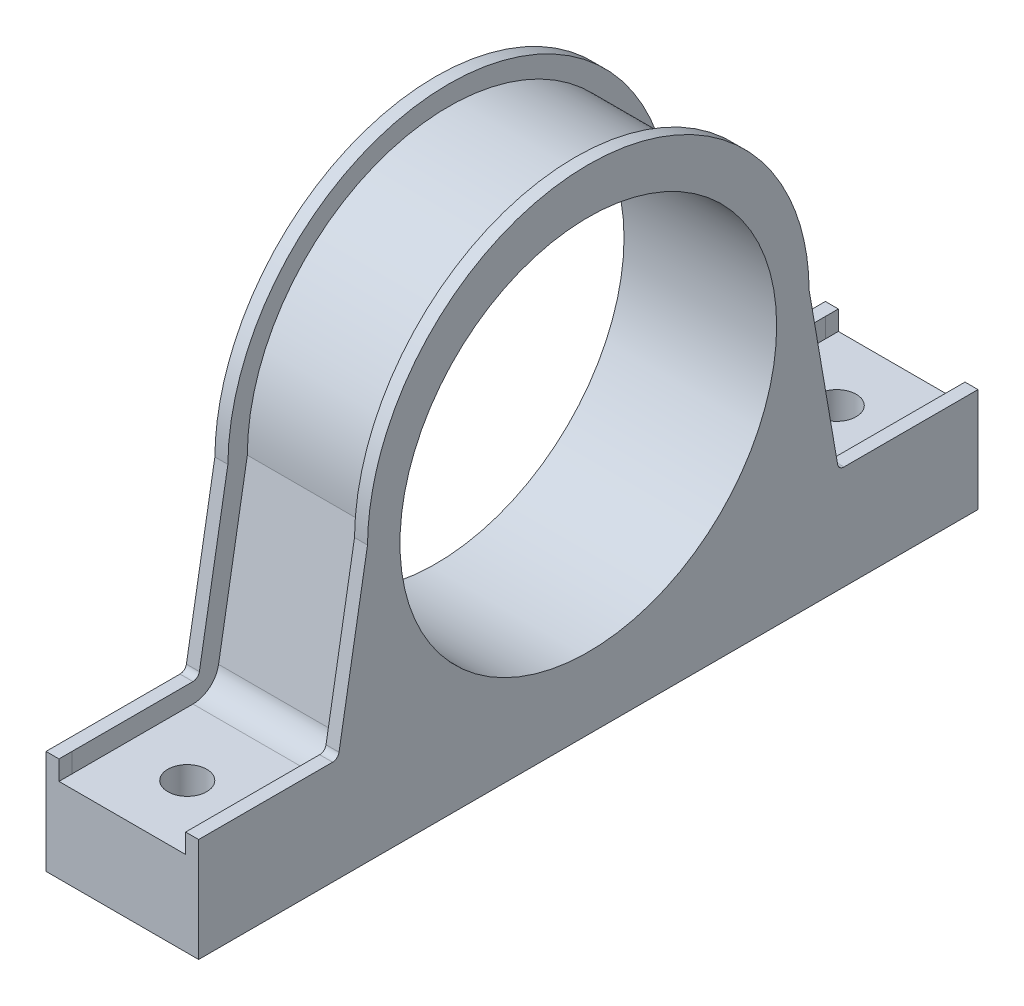
from build123d import *

# Parameters (mm, degrees)
SZKIC2_R                    = 29
DODANIE_WYCI_GNI_CIE2_DEPTH = 23.5
SZKIC3_R                    = 3
WYTNIJ_WYCI_GNI_CIE1_DEPTH  = 23.5
ZAOKR_GLENIE1_R             = 4
DODANIE_WYCI_GNI_CIE3_REACH = 82
WYTNIJ_WYCI_GNI_CIE2_DEPTH  = 23.5


with BuildPart() as part:
    # Szkic2 → Dodanie-wyciągnięcie2 (new body)
    with BuildSketch(Plane(origin=(0, 0, 0), x_dir=(0, 0, -1), z_dir=(1, 0, 0))):
        with BuildLine():
            Line((-60, -6.5), (60, -6.5))
            Line((60, -6.5), (60, 6.5))
            Line((60, 6.5), (36, 6.5))
            Line((36, 6.5), (31, 35.5))
            ThreePointArc((31, 35.5), (0, 66.5), (-31, 35.5))
            Line((-31, 35.5), (-36, 6.5))
            Line((-36, 6.5), (-60, 6.5))
            Line((-60, 6.5), (-60, -6.5))
        make_face()
        with Locations((0, 33.5)):
            Circle(SZKIC2_R, mode=Mode.SUBTRACT)
    extrude(amount=DODANIE_WYCI_GNI_CIE2_DEPTH)

    # Szkic3 → Wytnij-wyciągnięcie1 (cut)
    with BuildSketch(Plane(origin=(0, 6.5, 0), x_dir=(1, 0, 0), z_dir=(0, 1, 0))):
        with Locations((11.75, 50)):
            Circle(SZKIC3_R)
        with Locations((11.75, -50)):
            Circle(SZKIC3_R)
    extrude(amount=-WYTNIJ_WYCI_GNI_CIE1_DEPTH, mode=Mode.SUBTRACT)

    # Zaokrąglenie1
    zaokr_glenie1_edges = [part.edges().sort_by_distance(p)[0] for p in [
        (11.75, 6.5, -36),
        (11.75, 6.5, 36),
    ]]
    fillet(zaokr_glenie1_edges, radius=ZAOKR_GLENIE1_R)

    # Szkic4 → Dodanie-wyciągnięcie3 (add, up to next)
    with BuildSketch(Plane(origin=(0, 73.5, 0), x_dir=(-1, 0, 0), z_dir=(0, -1, 0)), mode=Mode.PRIVATE) as dodanie_wyci_gni_cie3_sk1:
        Polygon((0, 60), (0, 39.369362474), (0, 35.427522011), (0, 31), (0, -31), (0, -35.427522011), (0, -39.369362474), (0, -60), (-2, -60), (-2, -58), (-2, 58), (-2, 60), align=None)
    dodanie_wyci_gni_cie3_tool1 = extrude(dodanie_wyci_gni_cie3_sk1.sketch, amount=DODANIE_WYCI_GNI_CIE3_REACH, mode=Mode.PRIVATE) - part.part
    add(dodanie_wyci_gni_cie3_tool1.solids().sort_by_distance((1, 73.5, 0))[0])
    # Szkic4 → Dodanie-wyciągnięcie3 (add, up to next)
    with BuildSketch(Plane(origin=(0, 73.5, 0), x_dir=(-1, 0, 0), z_dir=(0, -1, 0)), mode=Mode.PRIVATE) as dodanie_wyci_gni_cie3_sk2:
        Polygon((-23.5, 39.369362474), (-23.5, 60), (-21.5, 60), (-21.5, 58), (-21.5, -58), (-21.5, -60), (-23.5, -60), (-23.5, -39.369362474), (-23.5, -35.427522011), (-23.5, -31), (-23.5, 31), (-23.5, 35.427522011), align=None)
    dodanie_wyci_gni_cie3_tool2 = extrude(dodanie_wyci_gni_cie3_sk2.sketch, amount=DODANIE_WYCI_GNI_CIE3_REACH, mode=Mode.PRIVATE) - part.part
    add(dodanie_wyci_gni_cie3_tool2.solids().sort_by_distance((22.5, 73.5, 0))[0])

    # Szkic5 → Wytnij-wyciągnięcie2 (cut)
    with BuildSketch(Plane(origin=(23.5, 0, 0), x_dir=(0, 0, -1), z_dir=(1, 0, 0))):
        Polygon((-60, 73.5), (-60, 9.5), (-58, 9.5), (-39.369362474, 9.5), (-39.369362474, 73.5), align=None)
        with BuildLine():
            Line((-39.369362474, 73.5), (-39.369362474, 9.5))
            ThreePointArc((-39.369362474, 9.5), (-38.725121416, 9.735177499), (-38.383902359, 10.330093083))
            Line((-38.383902359, 10.330093083), (-35.427522011, 27.477099097))
            Line((-35.427522011, 27.477099097), (-35.427522011, 73.5))
            Line((-35.427522011, 73.5), (-39.369362474, 73.5))
        make_face()
        with BuildLine():
            Line((-31, 73.5), (-31, 49.464240044))
            ThreePointArc((-31, 49.464240044), (0, 69.5), (31, 49.464240044))
            Line((31, 49.464240044), (31, 73.5))
            Line((31, 73.5), (-31, 73.5))
        make_face()
        with BuildLine():
            Line((-35.427522011, 73.5), (-35.427522011, 27.477099097))
            Line((-35.427522011, 27.477099097), (-33.998985816, 35.762609032))
            ThreePointArc((-33.998985816, 35.762609032), (-33.213712716, 42.769751553), (-31, 49.464240044))
            Line((-31, 49.464240044), (-31, 73.5))
            Line((-31, 73.5), (-35.427522011, 73.5))
        make_face()
        with BuildLine():
            Line((35.427522011, 73.5), (35.427522011, 27.477099097))
            Line((35.427522011, 27.477099097), (38.383902359, 10.330093083))
            ThreePointArc((38.383902359, 10.330093083), (38.725121416, 9.735177499), (39.369362474, 9.5))
            Line((39.369362474, 9.5), (39.369362474, 73.5))
            Line((39.369362474, 73.5), (35.427522011, 73.5))
        make_face()
        with BuildLine():
            Line((31, 73.5), (31, 49.464240044))
            ThreePointArc((31, 49.464240044), (33.213712716, 42.769751553), (33.998985816, 35.762609032))
            Line((33.998985816, 35.762609032), (35.427522011, 27.477099097))
            Line((35.427522011, 27.477099097), (35.427522011, 73.5))
            Line((35.427522011, 73.5), (31, 73.5))
        make_face()
        Polygon((39.369362474, 73.5), (39.369362474, 9.5), (58, 9.5), (60, 9.5), (60, 73.5), align=None)
    extrude(amount=-WYTNIJ_WYCI_GNI_CIE2_DEPTH, mode=Mode.SUBTRACT)


solid = part.part
